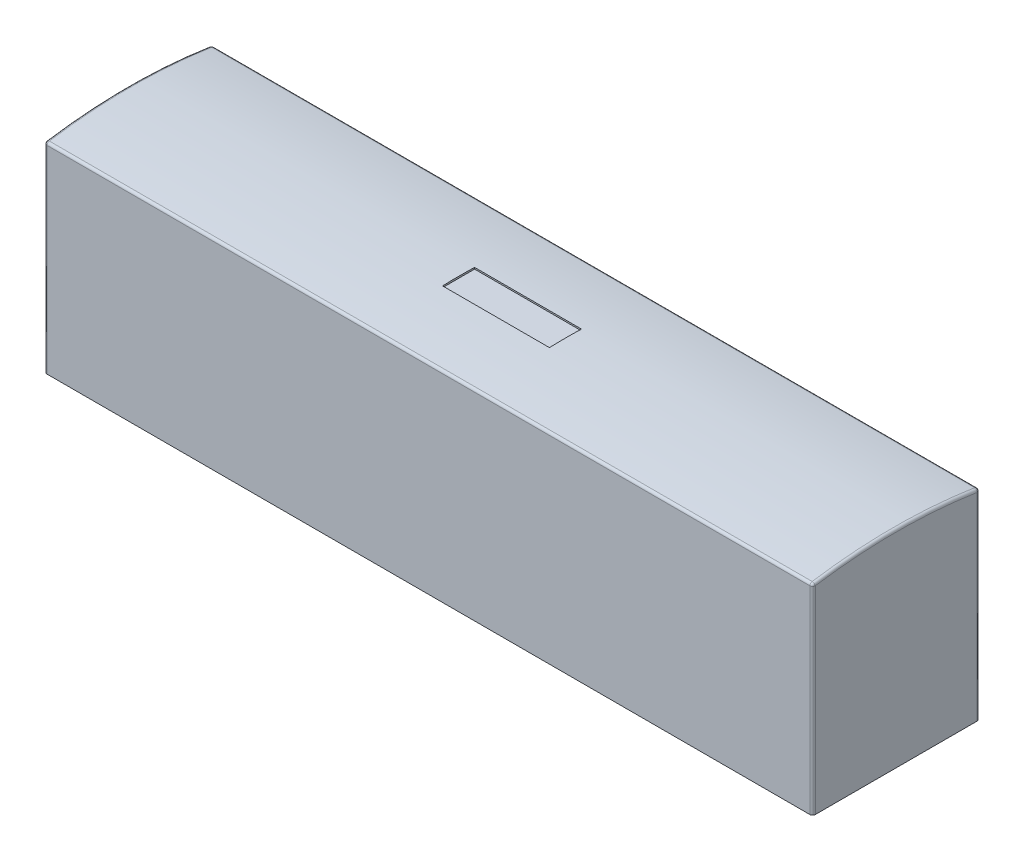
from build123d import *

# Parameters (mm, degrees)
SKETCH1_W           = 18.25625
SKETCH1_H           = 3.96875
BOSS_EXTRUDE1_DEPTH = 4.7625
BOSS_EXTRUDE2_DEPTH = 18.25625
SKETCH4_W           = 2.54
SKETCH4_H           = 0.762
CUT_EXTRUDE1_DEPTH  = 1.041687251
FILLET1_R           = 0.0635


with BuildPart() as part:
    # Sketch1 → Boss-Extrude1 (new body)
    with BuildSketch(Plane(origin=(0, 0, 0), x_dir=(1, 0, 0), z_dir=(0, 1, 0))):
        with Locations((9.128125, 1.984375)):
            Rectangle(SKETCH1_W, SKETCH1_H)
    extrude(amount=BOSS_EXTRUDE1_DEPTH)

    # Sketch2 → Boss-Extrude2 (add)
    with BuildSketch(Plane(origin=(18.25625, 0, 0), x_dir=(0, 0, -1), z_dir=(1, 0, 0))):
        with BuildLine():
            Line((0, 4.7625), (3.96875, 4.7625))
            ThreePointArc((3.96875, 4.7625), (1.984375, 4.918487251), (0, 4.7625))
        make_face()
    extrude(amount=-BOSS_EXTRUDE2_DEPTH)

    # Sketch4 → Cut-Extrude1 (cut, through all)
    with BuildSketch(Plane(origin=(0, 4.8768, 0), x_dir=(1, 0, 0), z_dir=(0, 1, 0))):
        with Locations((9.128125, 1.984375)):
            Rectangle(SKETCH4_W, SKETCH4_H)
    extrude(amount=CUT_EXTRUDE1_DEPTH, mode=Mode.SUBTRACT)

    # Fillet1
    fillet1_edges = [part.edges().sort_by_distance(p)[0] for p in [
        (18.25625, 4.918487251, -1.984375),
        (0, 4.918487251, -1.984375),
        (9.128125, 4.7625, -3.96875),
        (0, 2.38125, -3.96875),
        (18.25625, 2.38125, -3.96875),
        (18.25625, 2.38125, 0),
        (0, 2.38125, 0),
        (9.128125, 4.7625, 0),
    ]]
    fillet(fillet1_edges, radius=FILLET1_R)


solid = part.part
